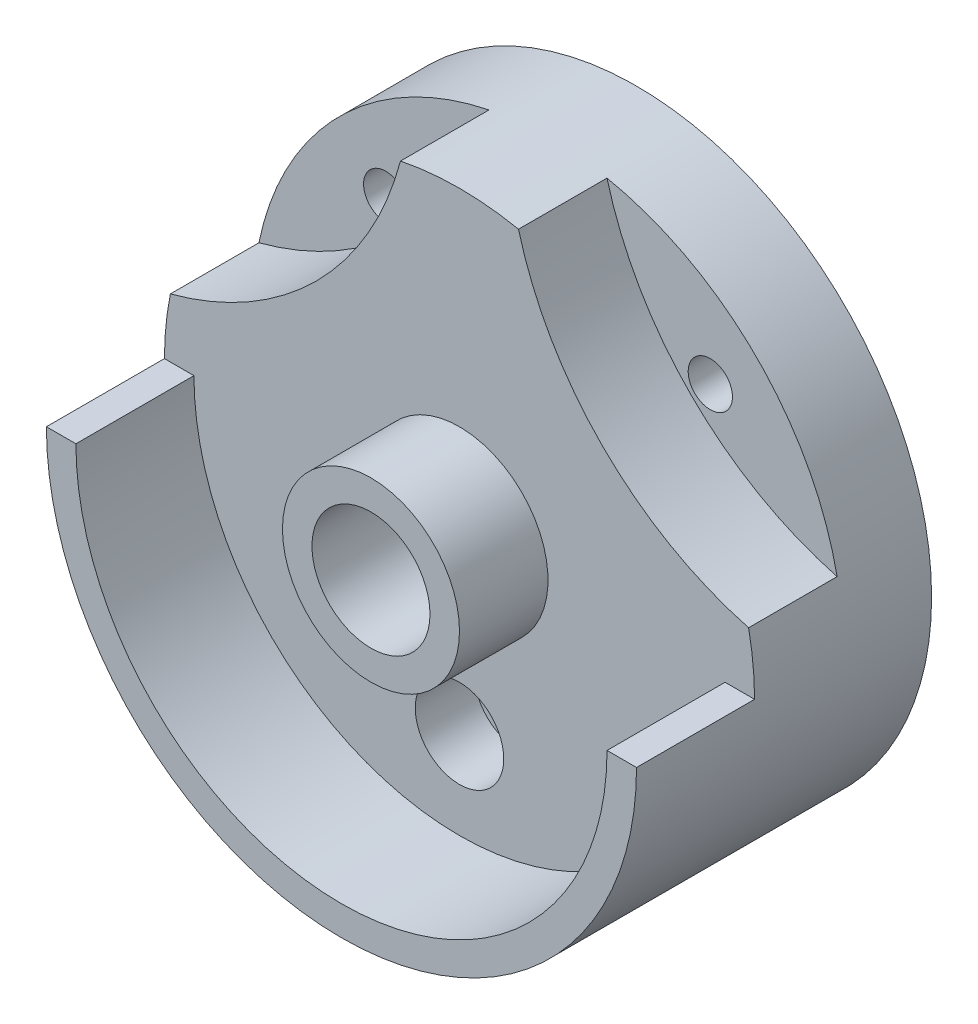
from build123d import *

# Parameters (mm, degrees)
SKETCH1_R           = 100
BOSS_EXTRUDE1_DEPTH = 100
SKETCH3_R           = 7.5
CUT_EXTRUDE2_DEPTH  = 30
CUT_EXTRUDE3_DEPTH  = 70
SKETCH5_W           = 200
SKETCH5_H           = 200
CUT_EXTRUDE4_DEPTH  = 70
BOSS_EXTRUDE2_DEPTH = 40
SKETCH7_R           = 15
CUT_EXTRUDE5_DEPTH  = 20
SKETCH8_R           = 5
CUT_EXTRUDE6_DEPTH  = 89
SKETCH9_R           = 25
CUT_EXTRUDE7_DEPTH  = 20
SKETCH10_R          = 30
BOSS_EXTRUDE4_DEPTH = 30
SKETCH12_R          = 20
CUT_EXTRUDE9_DEPTH  = 50
SKETCH13_R          = 20
CUT_EXTRUDE10_DEPTH = 50


with BuildPart() as part:
    # Sketch1 → Boss-Extrude1 (new body)
    with BuildSketch(Plane.XY):
        Circle(SKETCH1_R)
    extrude(amount=BOSS_EXTRUDE1_DEPTH)

    # Sketch3 → Cut-Extrude2 (cut)
    with BuildSketch(Plane(origin=(0, 0, 0), x_dir=(-1, 0, 0), z_dir=(0, 0, -1))):
        with Locations((-55, 55)):
            Circle(SKETCH3_R)
        with Locations((55, 55)):
            Circle(SKETCH3_R)
    extrude(amount=-CUT_EXTRUDE2_DEPTH, mode=Mode.SUBTRACT)

    # Sketch4 → Cut-Extrude3 (cut)
    with BuildSketch(Plane.XY.offset(100)):
        with BuildLine():
            ThreePointArc((-97.979589711, 20), (-48.511807343, 48.511807343), (-20, 97.979589711))
            ThreePointArc((-20, 97.979589711), (-70.710678119, 70.710678119), (-97.979589711, 20))
        make_face()
        with BuildLine():
            ThreePointArc((97.979589711, 20), (70.710678119, 70.710678119), (20, 97.979589711))
            ThreePointArc((20, 97.979589711), (48.511807343, 48.511807343), (97.979589711, 20))
        make_face()
    extrude(amount=-CUT_EXTRUDE3_DEPTH, mode=Mode.SUBTRACT)

    # Sketch5 → Cut-Extrude4 (cut)
    with BuildSketch(Plane.XY.offset(60)):
        Rectangle(SKETCH5_W, SKETCH5_H)
    extrude(amount=CUT_EXTRUDE4_DEPTH, mode=Mode.SUBTRACT)

    # Sketch6 → Boss-Extrude2 (add)
    with BuildSketch(Plane.XY.offset(60)):
        with BuildLine():
            Line((-100, 0), (-90, 0))
            ThreePointArc((-90, 0), (0, -90), (90, 0))
            Line((90, 0), (100, 0))
            ThreePointArc((100, 0), (0, -100), (-100, 0))
        make_face()
    extrude(amount=BOSS_EXTRUDE2_DEPTH)

    # Sketch7 → Cut-Extrude5 (cut)
    with BuildSketch(Plane.XY.offset(60)):
        with Locations((0, -60)):
            Circle(SKETCH7_R)
    extrude(amount=-CUT_EXTRUDE5_DEPTH, mode=Mode.SUBTRACT)

    # Sketch8 → Cut-Extrude6 (cut)
    with BuildSketch(Plane.XY.offset(40)):
        with Locations((0, -60)):
            Circle(SKETCH8_R)
    extrude(amount=-CUT_EXTRUDE6_DEPTH, mode=Mode.SUBTRACT)

    # Sketch9 → Cut-Extrude7 (cut)
    with BuildSketch(Plane(origin=(0, 0, 0), x_dir=(-1, 0, 0), z_dir=(0, 0, -1))):
        with Locations((0, -60)):
            Circle(SKETCH9_R)
    extrude(amount=-CUT_EXTRUDE7_DEPTH, mode=Mode.SUBTRACT)

    # Sketch10 → Boss-Extrude4 (add)
    with BuildSketch(Plane.XY.offset(60)):
        Circle(SKETCH10_R)
    extrude(amount=BOSS_EXTRUDE4_DEPTH)

    # Sketch12 → Cut-Extrude9 (cut)
    with BuildSketch(Plane.XY.offset(90)):
        Circle(SKETCH12_R)
    extrude(amount=-CUT_EXTRUDE9_DEPTH, mode=Mode.SUBTRACT)

    # Sketch13 → Cut-Extrude10 (cut)
    with BuildSketch(Plane.XY.offset(40)):
        Circle(SKETCH13_R)
    extrude(amount=-CUT_EXTRUDE10_DEPTH, mode=Mode.SUBTRACT)


solid = part.part
